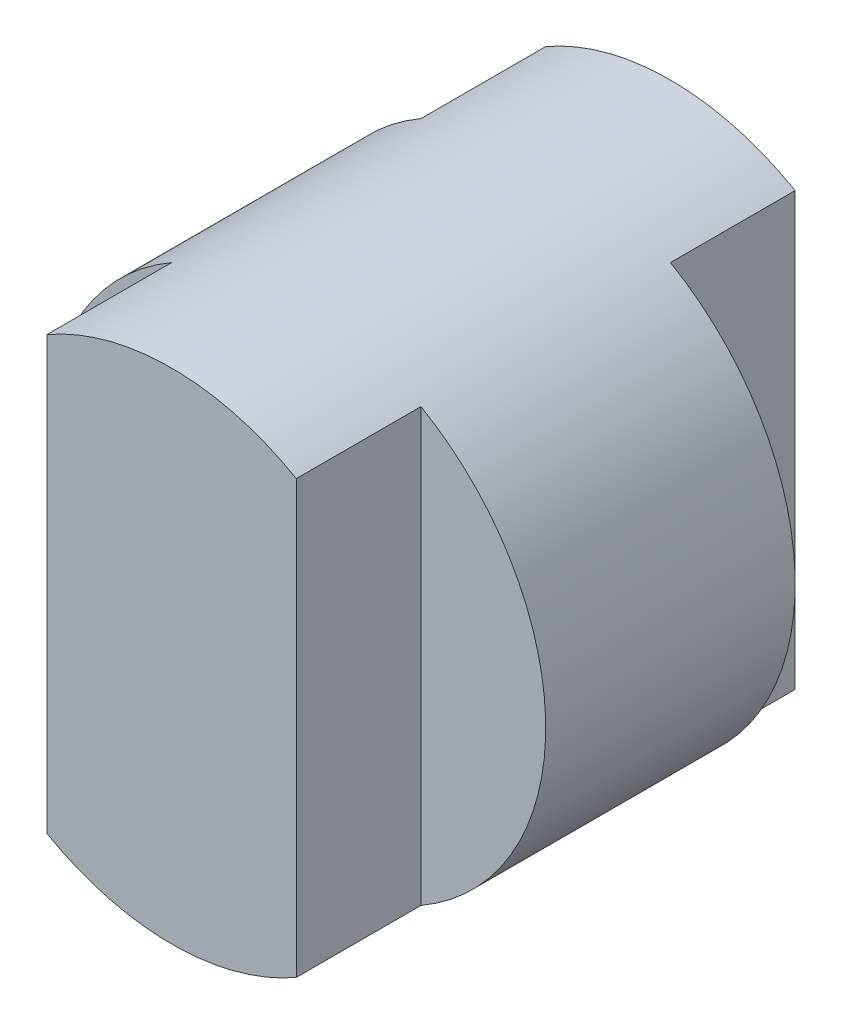
from build123d import *

# Parameters (mm, degrees)
SKETCH1_R           = 2
BOSS_EXTRUDE1_DEPTH = 4
CUT_EXTRUDE1_DEPTH  = 5
SKETCH3_W           = 1
SKETCH3_H           = 1
CUT_EXTRUDE2_DEPTH  = 5


with BuildPart() as part:
    # Sketch1 → Boss-Extrude1 (new body)
    with BuildSketch(Plane.XY):
        Circle(SKETCH1_R)
    extrude(amount=BOSS_EXTRUDE1_DEPTH)

    # Sketch2 → Cut-Extrude1 (cut, symmetric)
    with BuildSketch(Plane(origin=(0, 0, 0), x_dir=(1, 0, 0), z_dir=(0, 1, 0))):
        Polygon((2, -3), (1, -3), (1, -4.221507546), (-1, -4.26455627), (-1, -3), (-2.31386892, -3), (-2.31386892, -1), (-1, -1), (-1, 0.234035397), (-2.586760402, 0.199881392), (-2.489753088, -4.306979917), (2, -4.619024092), (2.554571986, -4.221507546), align=None)
    extrude(amount=CUT_EXTRUDE1_DEPTH, both=True, mode=Mode.SUBTRACT)

    # Sketch3 → Cut-Extrude2 (cut, symmetric)
    with BuildSketch(Plane(origin=(0, 0, 0), x_dir=(1, 0, 0), z_dir=(0, 1, 0))):
        with Locations((1.5, -0.5)):
            Rectangle(SKETCH3_W, SKETCH3_H)
    extrude(amount=CUT_EXTRUDE2_DEPTH, both=True, mode=Mode.SUBTRACT)


solid = part.part
